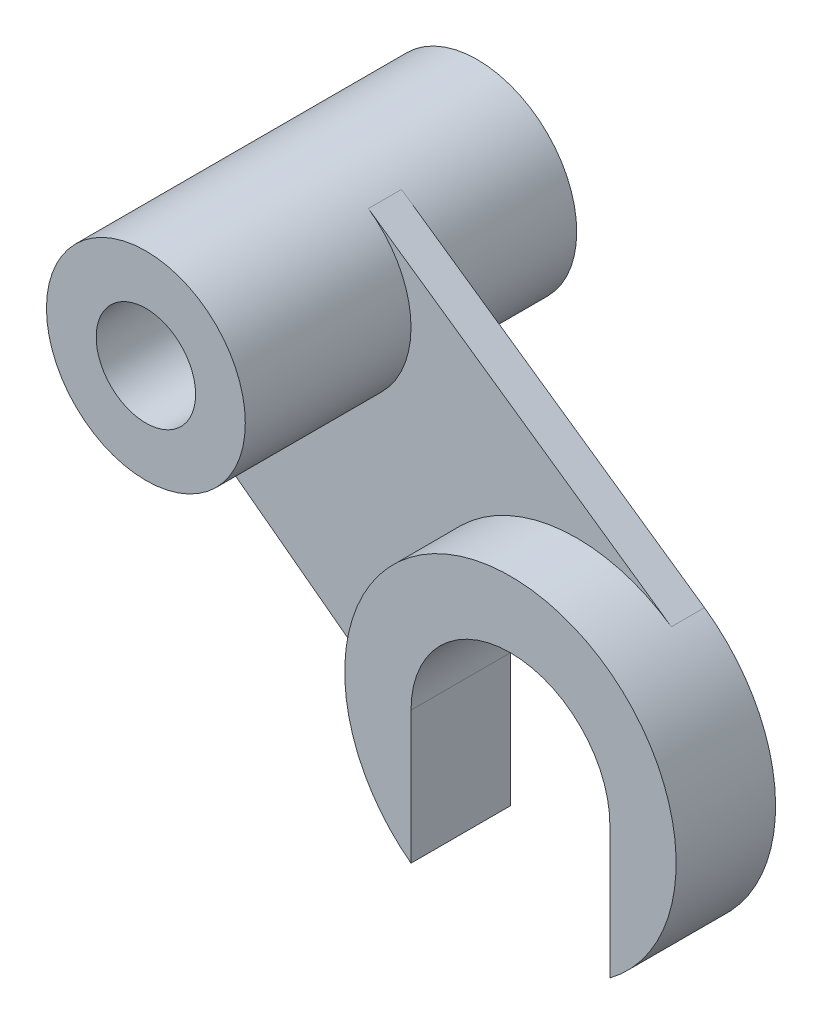
from build123d import *
from build123d.topology import SkipClean

# Parameters (mm, degrees)
BOSS_EXTRUDE1_DEPTH      = 50
BOSS_EXTRUDE1_DEPTH_BACK = 50
SKETCH1_R                = 30
SKETCH1_R_2              = 15
BOSS_EXTRUDE2_DEPTH      = 20
BOSS_EXTRUDE2_DEPTH_BACK = 10
BOSS_EXTRUDE3_DEPTH      = 10
CUT_EXTRUDE1_DEPTH       = 184.847763109
CUT_EXTRUDE1_DEPTH_BACK  = 184.847763109
SKETCH9_R                = 15


with BuildPart() as part:
    # Sketch1 → Boss-Extrude1 (new, two sides: drawn at the far end of the back side and taken through both)
    with BuildSketch(Plane.XY.offset(-BOSS_EXTRUDE1_DEPTH_BACK)):
        Circle(SKETCH1_R)
        Circle(SKETCH1_R_2, mode=Mode.SUBTRACT)
    extrude(amount=BOSS_EXTRUDE1_DEPTH + BOSS_EXTRUDE1_DEPTH_BACK)



with BuildPart() as body_2:
    # Sketch2 → Boss-Extrude2 (new, two sides: drawn at the far end of the back side and taken through both)
    with BuildSketch(Plane.XY.offset(-BOSS_EXTRUDE2_DEPTH_BACK)):
        with BuildLine():
            Line((110, -80), (110, -120))
            ThreePointArc((110, -120), (80, -30), (50, -120))
            Line((50, -120), (50, -80))
            ThreePointArc((50, -80), (80, -50), (110, -80))
        make_face()
    extrude(amount=BOSS_EXTRUDE2_DEPTH + BOSS_EXTRUDE2_DEPTH_BACK)


with BuildPart() as part_1:
    add(part.part)

    add(body_2.part)  # Boss-Extrude3 merges body 2
    # Sketch3 → Boss-Extrude3 (add)
    with BuildSketch(Plane.XY):
        Polygon((17.129116361, 24.629116361), (108.548527268, -38.951472732), (50, -120), (-30, -60), (-30, 0), align=None)
    extrude(amount=-BOSS_EXTRUDE3_DEPTH)

    # Sketch9 → Cut-Extrude1 (cut, two sides: drawn at the far end of the back side and taken through both)
    with SkipClean():  # the faces are left unmerged after this step: merging them gives an invalid solid
        with BuildSketch(Plane.XY.offset(-CUT_EXTRUDE1_DEPTH_BACK)):
            Circle(SKETCH9_R)
            with BuildLine():
                Line((50, -80), (50, -120))
                Line((50, -120), (110, -120))
                Line((110, -120), (110, -80))
                ThreePointArc((110, -80), (80, -50), (50, -80))
            make_face()
        extrude(amount=CUT_EXTRUDE1_DEPTH + CUT_EXTRUDE1_DEPTH_BACK, mode=Mode.SUBTRACT)
    add(part_1.part.scale(1), mode=Mode.REPLACE)  # the faces are merged on a copy


solid = part_1.part
